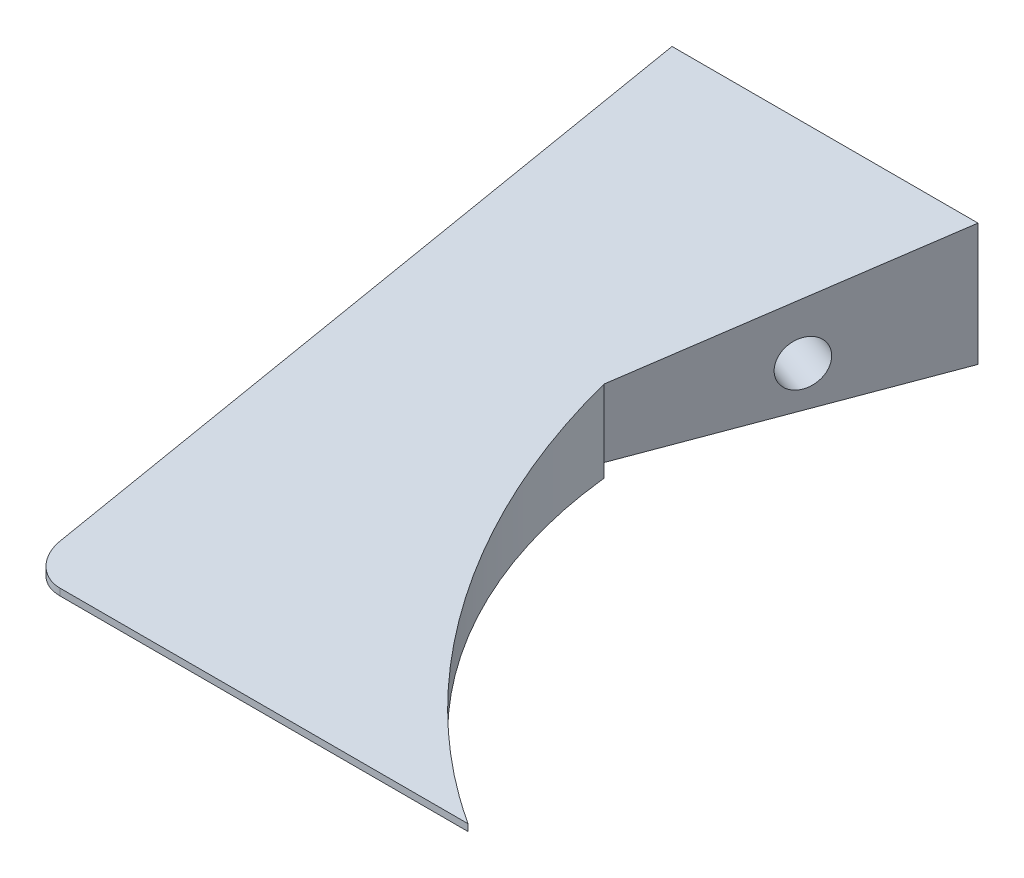
from build123d import *

# Parameters (mm, degrees)
ESBO_O1_W                                      = 130
ESBO_O1_H                                      = 20
RESSALTO_EXTRUS_O1_DEPTH                       = 95
CORTE_EXTRUS_O2_REACH                          = 22
CORTE_EXTRUS_O4_DEPTH                          = 1
CORTE_EXTRUS_O4_DEPTH_BACK                     = 66
BROCA_DE_ROSQUEAR_DE_CANO_PARA_TARRAXA_D_D     = 6.579997
BROCA_DE_ROSQUEAR_DE_CANO_PARA_TARRAXA_D_DEPTH = 10
BROCA_DE_ROSQUEAR_DE_CANO_PARA_TARRAXA_D_TIP   = 1.976830535
BROCA_DE_ROSQUEAR_DE_CANO_PARA_TARRA_2_D       = 6.579997
BROCA_DE_ROSQUEAR_DE_CANO_PARA_TARRA_2_DEPTH   = 10
BROCA_DE_ROSQUEAR_DE_CANO_PARA_TARRA_2_TIP     = 1.976830535
FILETE2_R                                      = 5
ESBO_O38_W                                     = 45
ESBO_O38_H                                     = 2
CORTE_EXTRUS_O9_DEPTH                          = 40


with BuildPart() as part:
    # Esboço1 → Ressalto-extrusão1 (new body)
    with BuildSketch(Plane.XY):
        Rectangle(ESBO_O1_W, ESBO_O1_H)
    extrude(amount=RESSALTO_EXTRUS_O1_DEPTH)

    # Esboço2 → Corte-extrusão2 (cut, up to next)
    with BuildSketch(Plane(origin=(0, 10, 0), x_dir=(1, 0, 0), z_dir=(0, 1, 0)), mode=Mode.PRIVATE) as corte_extrus_o2_sk1:
        with BuildLine():
            Line((65, 0), (-20, 0))
            Line((-20, 0), (-35, -40))
            ThreePointArc((-35, -40), (-23.93419305, -71.594486486), (0, -95))
            Line((0, -95), (65, -95))
            Line((65, -95), (65, 0))
        make_face()
    corte_extrus_o2_tool1 = extrude(corte_extrus_o2_sk1.sketch, amount=-CORTE_EXTRUS_O2_REACH, mode=Mode.PRIVATE) & part.part
    add(corte_extrus_o2_tool1.solids().sort_by_distance((19.507418, 10, 46.266943))[0], mode=Mode.SUBTRACT)

    # Esboço13 → Corte-extrusão4 (cut, two sides)
    with BuildSketch(Plane.ZY.offset(65)) as corte_extrus_o4_sk:
        Polygon((-200.200134404, 50.040026881), (0, 10), (95, -9), (295.200134404, -49.040026881), (375.280188165, 351.360241926), (-120.120080642, 450.440295688), align=None)
    extrude(amount=CORTE_EXTRUS_O4_DEPTH, mode=Mode.SUBTRACT)
    extrude(corte_extrus_o4_sk.sketch, amount=-CORTE_EXTRUS_O4_DEPTH_BACK, mode=Mode.SUBTRACT)

    # Broca de rosquear de cano para tarraxa d
    with Locations(Plane.ZY.offset(65)):
        with Locations((20, -2)):
            Hole(BROCA_DE_ROSQUEAR_DE_CANO_PARA_TARRAXA_D_D / 2, depth=BROCA_DE_ROSQUEAR_DE_CANO_PARA_TARRAXA_D_DEPTH)
            with Locations((0, 0, -(BROCA_DE_ROSQUEAR_DE_CANO_PARA_TARRAXA_D_DEPTH + BROCA_DE_ROSQUEAR_DE_CANO_PARA_TARRAXA_D_TIP / 2))):  # 118° drill point
                Cone(0, BROCA_DE_ROSQUEAR_DE_CANO_PARA_TARRAXA_D_D / 2, BROCA_DE_ROSQUEAR_DE_CANO_PARA_TARRAXA_D_TIP, mode=Mode.SUBTRACT)

    # Broca de rosquear de cano para tarra 2
    with Locations(Plane(origin=(-17.534246575, 0, -6.575342466), x_dir=(0.351123442, 0, -0.936329178), z_dir=(0.936329178, 0, 0.351123442))):
        with Locations((-27.022468832, -2)):
            Hole(BROCA_DE_ROSQUEAR_DE_CANO_PARA_TARRA_2_D / 2, depth=BROCA_DE_ROSQUEAR_DE_CANO_PARA_TARRA_2_DEPTH)
            with Locations((0, 0, -(BROCA_DE_ROSQUEAR_DE_CANO_PARA_TARRA_2_DEPTH + BROCA_DE_ROSQUEAR_DE_CANO_PARA_TARRA_2_TIP / 2))):  # 118° drill point
                Cone(0, BROCA_DE_ROSQUEAR_DE_CANO_PARA_TARRA_2_D / 2, BROCA_DE_ROSQUEAR_DE_CANO_PARA_TARRA_2_TIP, mode=Mode.SUBTRACT)

    # Filete2
    filete2_edges = [part.edges().sort_by_distance(p)[0] for p in [
        (-65, -9.5, 95),
    ]]
    fillet(filete2_edges, radius=FILETE2_R)

    # Esboço38 → Corte-extrusão9 (cut)
    with BuildSketch(Plane(origin=(0, 0, 0), x_dir=(-1, 0, 0), z_dir=(0, 0, -1))):
        with Locations((42.5, -9)):
            Rectangle(ESBO_O38_W, ESBO_O38_H)
    extrude(amount=-CORTE_EXTRUS_O9_DEPTH, mode=Mode.SUBTRACT)


solid = part.part
